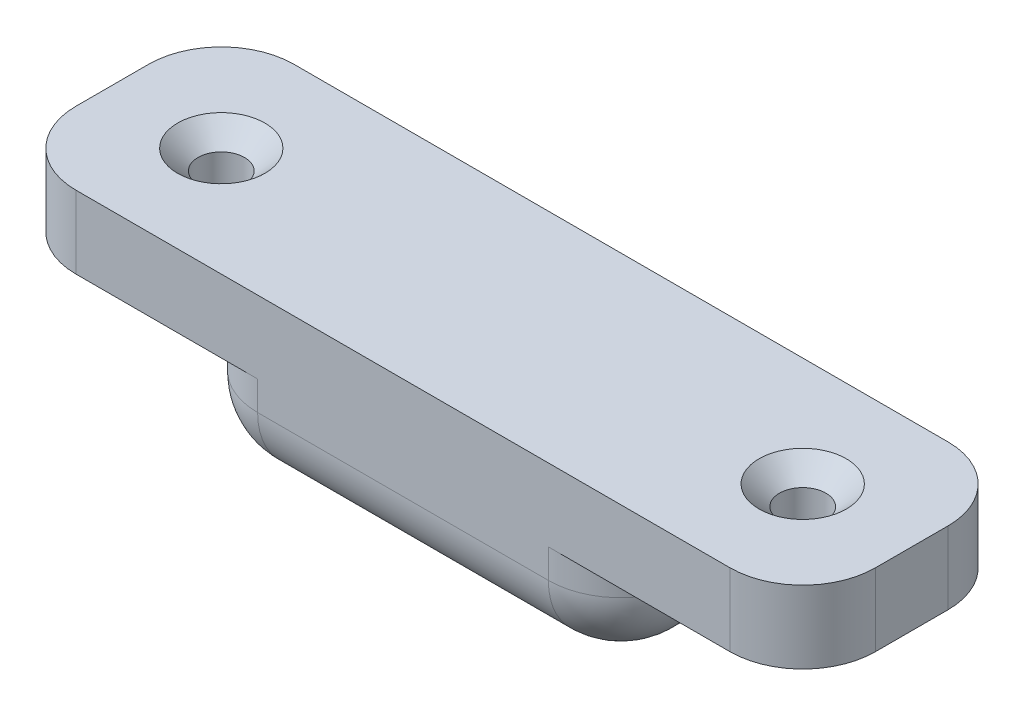
from build123d import *

# Parameters (mm, degrees)
BOSS_EXTRU_1_DEPTH                                 = 15
FRAISAGE_POUR_VIS_T_TE_FRAIS_E_CRUCIFO_D           = 3.2
FRAISAGE_POUR_VIS_T_TE_FRAIS_E_CRUCIFO_CSINK_D     = 6
FRAISAGE_POUR_VIS_T_TE_FRAIS_E_CRUCIFO_CSINK_ANGLE = 92
CONG_2_R                                           = 5


with BuildPart() as part:
    # Esquisse1 → Boss.-Extru.1 (new body)
    with BuildSketch(Plane.XY):
        Polygon((27.5, 6), (-27.5, 6), (-27.5, 1), (-15, 1), (-15, -6), (15, -6), (15, 1), (27.5, 1), align=None)
    extrude(amount=BOSS_EXTRU_1_DEPTH)

    # Fraisage pour vis à tête fraisée cruciforme M31 (through all)
    with Locations(Plane(origin=(0, 6, 0), x_dir=(1, 0, 0), z_dir=(0, 1, 0))):
        with Locations((-20, -7.5), (20, -7.5)):
            CounterSinkHole(FRAISAGE_POUR_VIS_T_TE_FRAIS_E_CRUCIFO_D / 2, FRAISAGE_POUR_VIS_T_TE_FRAIS_E_CRUCIFO_CSINK_D / 2, counter_sink_angle=FRAISAGE_POUR_VIS_T_TE_FRAIS_E_CRUCIFO_CSINK_ANGLE)

    # Congé2
    cong_2_edges = [part.edges().sort_by_distance(p)[0] for p in [
        (-15, -2.5, 15),
        (-27.5, 3.5, 0),
        (0, -6, 15),
        (15, -6, 7.5),
        (-15, -6, 7.5),
        (15, -2.5, 15),
        (27.5, 3.5, 15),
        (-27.5, 3.5, 15),
        (27.5, 3.5, 0),
        (15, -2.5, 0),
        (0, -6, 0),
        (-15, -2.5, 0),
    ]]
    fillet(cong_2_edges, radius=CONG_2_R)


solid = part.part
